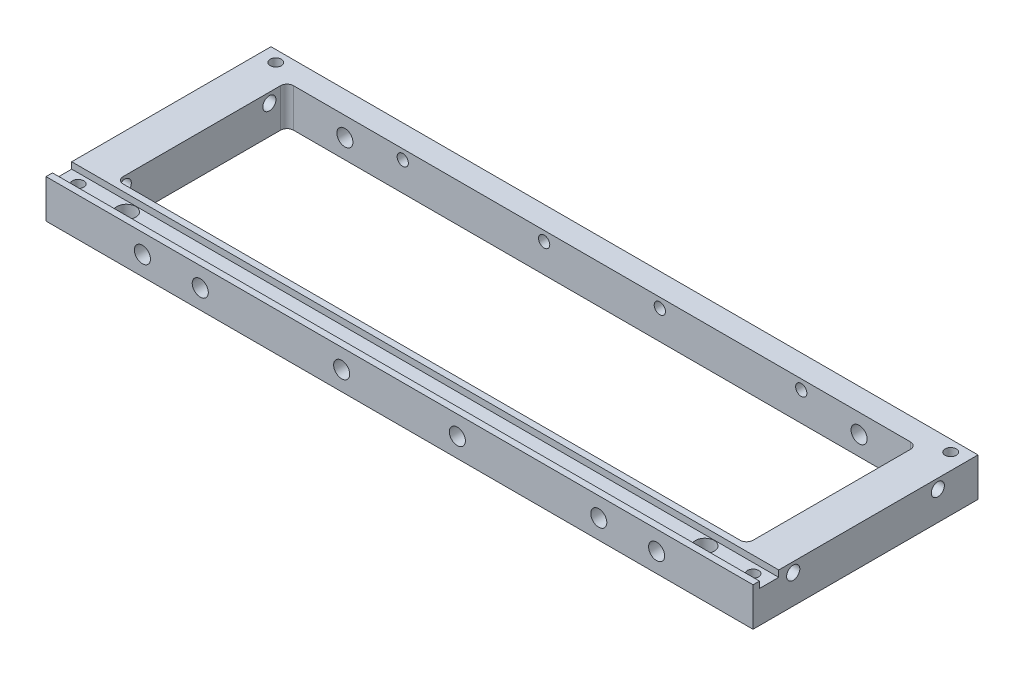
from build123d import *

# Parameters (mm, degrees)
SKETCH1_W                          = 110
SKETCH1_H                          = 35
BOSS_EXTRUDE1_DEPTH                = 6
SKETCH2_W                          = 98
SKETCH2_H                          = 26.5
CUT_EXTRUDE1_DEPTH                 = 6
SKETCH3_W                          = 110
SKETCH3_H                          = 3
CUT_EXTRUDE2_DEPTH                 = 1
CBORE_FOR_M2_5_SHCS1_D             = 2.9
CBORE_FOR_M2_5_SHCS1_CBORE_D       = 4.6
CBORE_FOR_M2_5_SHCS1_CBORE_DEPTH   = 2.5
FILLET1_R                          = 1
TAP_DRILL_FOR_M2_2X0_45_TAP1_D     = 1.75
TAP_DRILL_FOR_M3X0_5_TAP1_D        = 2.5
TAP_DRILL_FOR_M3X0_5_TAP1_DEPTH    = 6
TAP_DRILL_FOR_M3X0_5_TAP1_TIP      = 0.751075774
SKETCH17_W                         = 10
SKETCH17_H                         = 3
SKETCH17_W_2                       = 14
CUT_EXTRUDE3_DEPTH                 = 4
FILLET2_R                          = 0.5
TAP_DRILL_FOR_M3X0_5_TAP2_D        = 2.5
TAP_DRILL_FOR_M3X0_5_TAP2_DEPTH    = 6
TAP_DRILL_FOR_M3X0_5_TAP2_TIP      = 0.751075774
TAP_DRILL_FOR_M2_2X0_45_TAP2_D     = 1.75
TAP_DRILL_FOR_M2_2X0_45_TAP2_DEPTH = 6
TAP_DRILL_FOR_M2_2X0_45_TAP2_TIP   = 0.525753042
TAP_DRILL_FOR_M2_5X0_45_TAP2_D     = 2.05


with BuildPart() as part:
    # Sketch1 → Boss-Extrude1 (new body)
    with BuildSketch(Plane(origin=(0, 0, 0), x_dir=(1, 0, 0), z_dir=(0, 1, 0))):
        with Locations((55, 17.5)):
            Rectangle(SKETCH1_W, SKETCH1_H)
    extrude(amount=BOSS_EXTRUDE1_DEPTH)

    # Sketch2 → Cut-Extrude1 (cut)
    with BuildSketch(Plane(origin=(0, 6, 0), x_dir=(1, 0, 0), z_dir=(0, 1, 0))):
        with Locations((55, 18.25)):
            Rectangle(SKETCH2_W, SKETCH2_H)
    extrude(amount=-CUT_EXTRUDE1_DEPTH, mode=Mode.SUBTRACT)

    # Sketch3 → Cut-Extrude2 (cut)
    with BuildSketch(Plane(origin=(0, 6, 0), x_dir=(1, 0, 0), z_dir=(0, 1, 0))):
        with Locations((55, 2.5)):
            Rectangle(SKETCH3_W, SKETCH3_H)
    extrude(amount=-CUT_EXTRUDE2_DEPTH, mode=Mode.SUBTRACT)

    # CBORE for M2.5 SHCS1 (through all)
    with Locations(Plane(origin=(0, 0, 0), x_dir=(-1, 0, 0), z_dir=(0, -1, 0))):
        with Locations((-100, 2.5), (-10, 2.5)):
            CounterBoreHole(CBORE_FOR_M2_5_SHCS1_D / 2, CBORE_FOR_M2_5_SHCS1_CBORE_D / 2, CBORE_FOR_M2_5_SHCS1_CBORE_DEPTH)

    # Fillet1
    fillet1_edges = [part.edges().sort_by_distance(p)[0] for p in [
        (6, 3, -5),
        (6, 3, -31.5),
        (104, 3, -31.5),
        (104, 3, -5),
    ]]
    fillet(fillet1_edges, radius=FILLET1_R)

    # Tap Drill for M2.2x0.45 Tap1 (through all)
    with Locations(Plane(origin=(0, 0, 0), x_dir=(-1, 0, 0), z_dir=(0, -1, 0))):
        with Locations((-2.5, 2.5), (-107.5, 2.5), (-107.5, 33.25), (-2.5, 33.25)):
            Hole(TAP_DRILL_FOR_M2_2X0_45_TAP1_D / 2)

    # Tap Drill for M3x0.5 Tap1
    with Locations(Plane.XY):
        with Locations((15, 3), (24, 3), (46, 3), (64, 3), (86, 3), (95, 3)):
            Hole(TAP_DRILL_FOR_M3X0_5_TAP1_D / 2, depth=TAP_DRILL_FOR_M3X0_5_TAP1_DEPTH)
            with Locations((0, 0, -(TAP_DRILL_FOR_M3X0_5_TAP1_DEPTH + TAP_DRILL_FOR_M3X0_5_TAP1_TIP / 2))):  # 118° drill point
                Cone(0, TAP_DRILL_FOR_M3X0_5_TAP1_D / 2, TAP_DRILL_FOR_M3X0_5_TAP1_TIP, mode=Mode.SUBTRACT)

    # Sketch17 → Cut-Extrude3 (cut)
    with BuildSketch(Plane.XZ):
        with Locations((55, -2.5)):
            Rectangle(SKETCH17_W, SKETCH17_H)
        with Locations((35.5, -2.5)):
            Rectangle(SKETCH17_W_2, SKETCH17_H)
        with Locations((74.5, -2.5)):
            Rectangle(SKETCH17_W_2, SKETCH17_H)
    extrude(amount=-CUT_EXTRUDE3_DEPTH, mode=Mode.SUBTRACT)

    # Fillet2
    fillet2_edges = [part.edges().sort_by_distance(p)[0] for p in [
        (50, 2, -4),
        (50, 2, -1),
        (60, 2, -1),
        (60, 2, -4),
        (28.5, 2, -4),
        (28.5, 2, -1),
        (42.5, 2, -1),
        (42.5, 2, -4),
        (67.5, 2, -4),
        (67.5, 2, -1),
        (81.5, 2, -1),
        (81.5, 2, -4),
    ]]
    fillet(fillet2_edges, radius=FILLET2_R)

    # Tap Drill for M3x0.5 Tap2
    with Locations(Plane(origin=(0, 0, -35), x_dir=(-1, 0, 0), z_dir=(0, 0, -1))):
        with Locations((-15, 3), (-95, 3)):
            Hole(TAP_DRILL_FOR_M3X0_5_TAP2_D / 2, depth=TAP_DRILL_FOR_M3X0_5_TAP2_DEPTH)
            with Locations((0, 0, -(TAP_DRILL_FOR_M3X0_5_TAP2_DEPTH + TAP_DRILL_FOR_M3X0_5_TAP2_TIP / 2))):  # 118° drill point
                Cone(0, TAP_DRILL_FOR_M3X0_5_TAP2_D / 2, TAP_DRILL_FOR_M3X0_5_TAP2_TIP, mode=Mode.SUBTRACT)

    # Tap Drill for M2.2x0.45 Tap2
    with Locations(Plane(origin=(0, 0, -35), x_dir=(-1, 0, 0), z_dir=(0, 0, -1))):
        with Locations((-24, 4.5), (-46, 4.5), (-64, 4.5), (-86, 4.5)):
            Hole(TAP_DRILL_FOR_M2_2X0_45_TAP2_D / 2, depth=TAP_DRILL_FOR_M2_2X0_45_TAP2_DEPTH)
            with Locations((0, 0, -(TAP_DRILL_FOR_M2_2X0_45_TAP2_DEPTH + TAP_DRILL_FOR_M2_2X0_45_TAP2_TIP / 2))):  # 118° drill point
                Cone(0, TAP_DRILL_FOR_M2_2X0_45_TAP2_D / 2, TAP_DRILL_FOR_M2_2X0_45_TAP2_TIP, mode=Mode.SUBTRACT)

    # Tap Drill for M2.5x0.45 Tap2 (through all)
    with Locations(Plane(origin=(110, 0, 0), x_dir=(0, 0, -1), z_dir=(1, 0, 0))):
        with Locations((6.25, 4.5), (28.75, 4.5)):
            Hole(TAP_DRILL_FOR_M2_5X0_45_TAP2_D / 2)


solid = part.part
